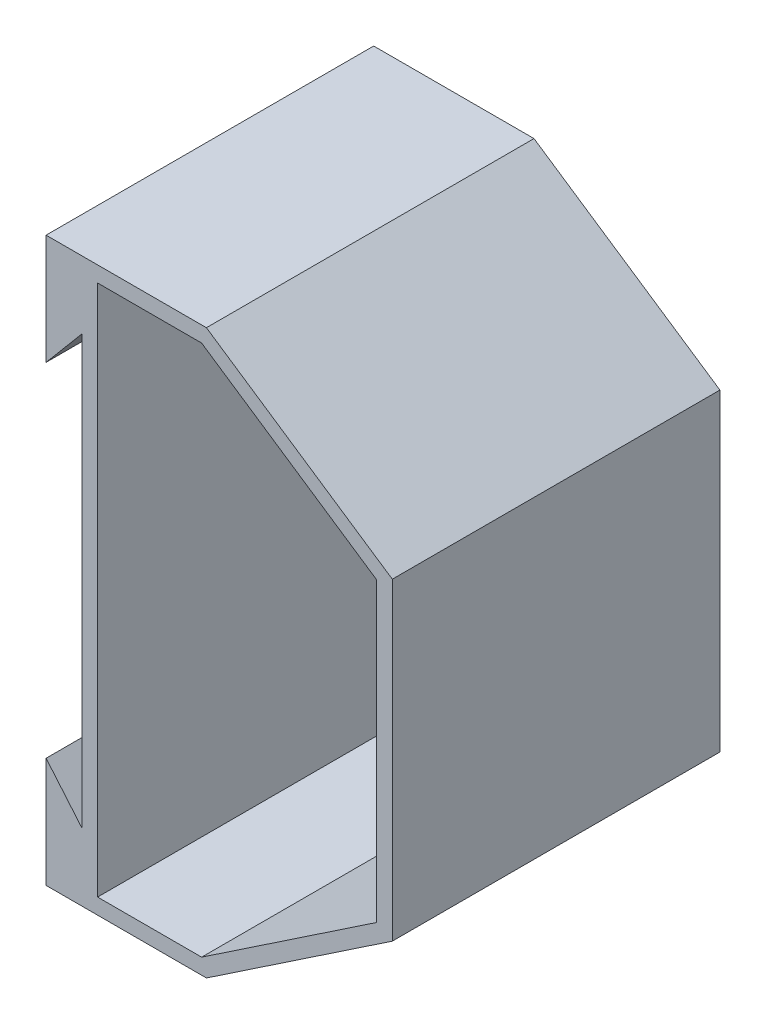
from build123d import *

# Parameters (mm, degrees)
SALIENTE_EXTRUIR1_DEPTH = 73.15


with BuildPart() as part:
    # Croquis1 → Saliente-Extruir1 (new body, symmetric)
    with BuildSketch(Plane.XY):
        Polygon((154.617693897, 70), (71.6, 125.75), (0, 125.75), (0, 76.55), (16, 95.55), (16, -95.55), (0, -76.55), (0, -125.75), (71.6, -125.75), (154.617693897, -70), align=None)
        Polygon((147.617693897, 66.26886769), (69.467692507, 118.75), (23, 118.75), (23, -118.75), (69.467692507, -118.75), (147.617693897, -66.26886769), align=None, mode=Mode.SUBTRACT)
    extrude(amount=SALIENTE_EXTRUIR1_DEPTH, both=True)


solid = part.part
